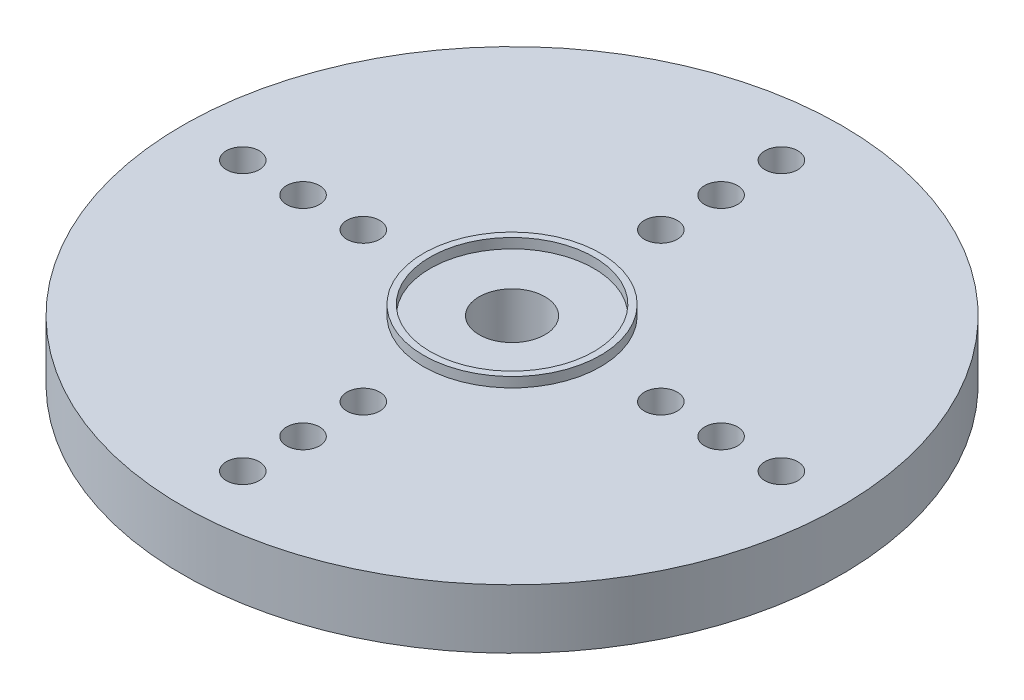
from build123d import *

# Parameters (mm, degrees)
SKETCH2_R           = 2.685
SKETCH2_R_2         = 2.485
BOSS_EXTRUDE1_DEPTH = 0.3
SKETCH4_R           = 0.5
CUT_EXTRUDE2_DEPTH  = 5.36
CIRPATTERN1_COUNT   = 4


with BuildPart() as part:
    # Sketch1 → Revolve2 (revolve)
    with BuildSketch(Plane.XY):
        Polygon((1, 2.26), (1, 4.06), (10, 4.06), (10, 2.26), (3.5, 2.26), (3.5, 0), (2.435, 0), (2.435, 2.26), align=None)
    revolve(axis=Axis((0, 0, 0), (0, 1, 0)))

    # Sketch2 → Boss-Extrude1 (add)
    with BuildSketch(Plane(origin=(0, 4.06, 0), x_dir=(1, 0, 0), z_dir=(0, 1, 0))):
        Circle(SKETCH2_R)
        Circle(SKETCH2_R_2, mode=Mode.SUBTRACT)
    extrude(amount=BOSS_EXTRUDE1_DEPTH)

    # Sketch4 → Cut-Extrude2 (cut, through all)
    with BuildSketch(Plane(origin=(0, 0, 0), x_dir=(1, 0, 0), z_dir=(0, 1, 0))):
        with Locations((0, 4.51375)):
            Circle(SKETCH4_R)
        with Locations((0, 6.3425)):
            Circle(SKETCH4_R)
        with Locations((0, 8.17125)):
            Circle(SKETCH4_R)
    cut_extrude2 = extrude(amount=CUT_EXTRUDE2_DEPTH, mode=Mode.SUBTRACT)

    # CirPattern1: Cut-Extrude2 ×4 about axis
    cirpattern1_axis = Axis((0, 0, 0), (0, 1, 0))
    for i in range(1, CIRPATTERN1_COUNT):
        add(cut_extrude2.rotate(cirpattern1_axis, i * 360 / CIRPATTERN1_COUNT), mode=Mode.SUBTRACT)


solid = part.part
